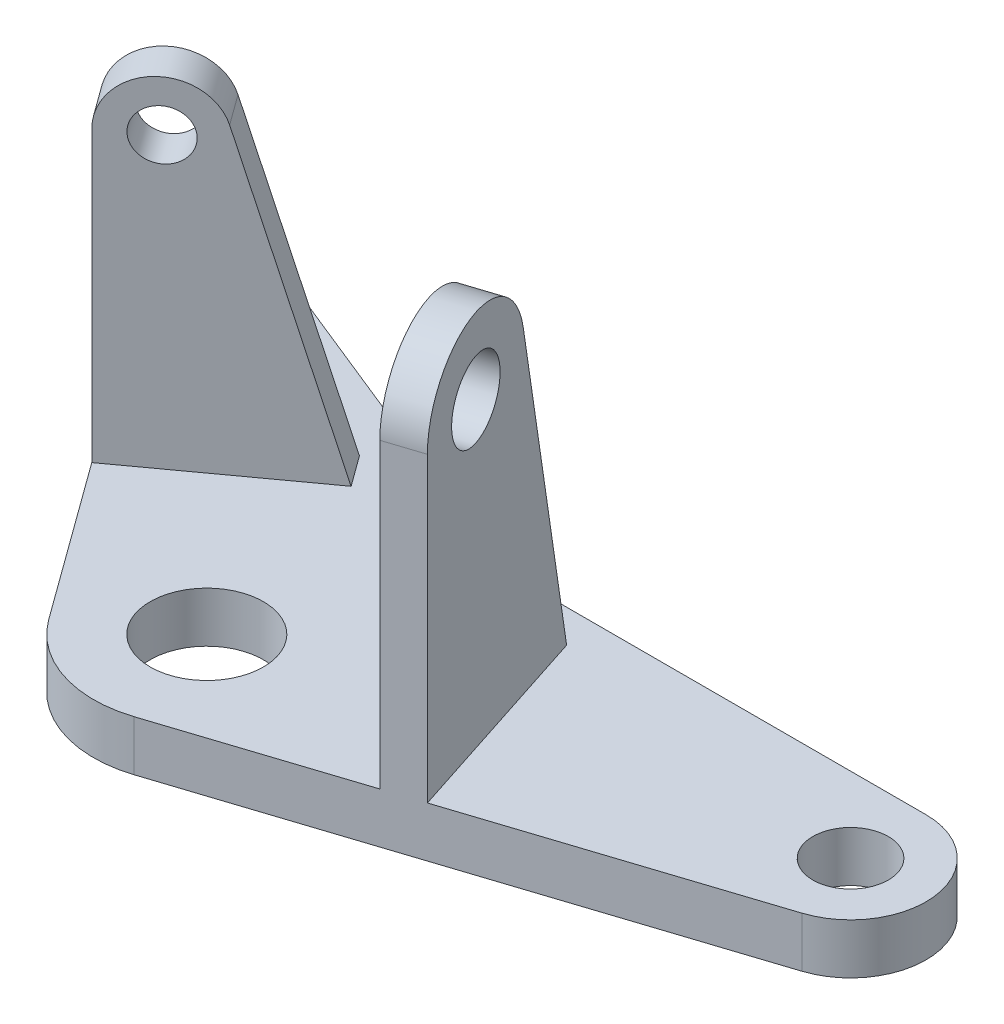
from build123d import *

# Parameters (mm, degrees)
SKETCH1_R           = 9
SKETCH1_R_2         = 6
SKETCH1_R_3         = 4
BOSS_EXTRUDE1_DEPTH = 8
SKETCH3_R           = 4
BOSS_EXTRUDE2_DEPTH = 3
SKETCH4_R           = 6
BOSS_EXTRUDE3_DEPTH = 3


with BuildPart() as part:
    # Sketch1 → Boss-Extrude1 (new body)
    with BuildSketch(Plane(origin=(0, 0, 0), x_dir=(1, 0, 0), z_dir=(0, 1, 0))):
        with BuildLine():
            Line((82, 32.334641746), (22.899881176, 32.334641746))
            ThreePointArc((22.899881176, 32.334641746), (14.88590337, 33.106300041), (7.166404253, 35.392919854))
            Line((7.166404253, 35.392919854), (-45.003147253, 56.470786852))
            ThreePointArc((-45.003147253, 56.470786852), (-54.304086029, 53.978607818), (-54.472135955, 44.351033997))
            Line((-54.472135955, 44.351033997), (-14.562305899, -10.580134541))
            ThreePointArc((-14.562305899, -10.580134541), (-5.562305899, -17.119017293), (5.562305899, -17.119017293))
            Line((5.562305899, -17.119017293), (85.708203932, 8.92196355))
            ThreePointArc((85.708203932, 8.92196355), (93.852260087, 22.211855326), (82, 32.334641746))
        make_face()
        Circle(SKETCH1_R, mode=Mode.SUBTRACT)
        with Locations((82, 20.334641746)):
            Circle(SKETCH1_R_2, mode=Mode.SUBTRACT)
        with Locations((-48, 49.053316016)):
            Circle(SKETCH1_R_3, mode=Mode.SUBTRACT)
    extrude(amount=BOSS_EXTRUDE1_DEPTH)

    # Sketch3 → Boss-Extrude2 (add, symmetric)
    with BuildSketch(Plane(origin=(-19.984698578, 0, -27.506577809), x_dir=(0.809016994, 0, -0.587785252), z_dir=(0.587785252, 0, 0.809016994))):
        with BuildLine():
            Line((-18, 8), (11.512683232, 8))
            Line((11.512683232, 8), (-2.309906432, 56.205098847))
            ThreePointArc((-2.309906432, 56.205098847), (-11.113384808, 61.92214455), (-18, 54))
            Line((-18, 54), (-18, 8))
        make_face()
        with Locations((-10, 54)):
            Circle(SKETCH3_R, mode=Mode.SUBTRACT)
    extrude(amount=BOSS_EXTRUDE2_DEPTH, both=True)

    # Sketch4 → Boss-Extrude3 (add, symmetric)
    with BuildSketch(Plane(origin=(32.335921554, 0, -10.506577809), x_dir=(-0.309016994, 0, -0.951056516), z_dir=(0.951056516, 0, -0.309016994))):
        with BuildLine():
            Line((-18, 8), (-18, 56))
            ThreePointArc((-18, 56), (-7.254341559, 67.934262744), (5.737771209, 58.49494029))
            Line((5.737771209, 58.49494029), (16.470802099, 8))
            Line((16.470802099, 8), (-18, 8))
        make_face()
        with Locations((-6, 56)):
            Circle(SKETCH4_R, mode=Mode.SUBTRACT)
    extrude(amount=BOSS_EXTRUDE3_DEPTH, both=True)


solid = part.part
